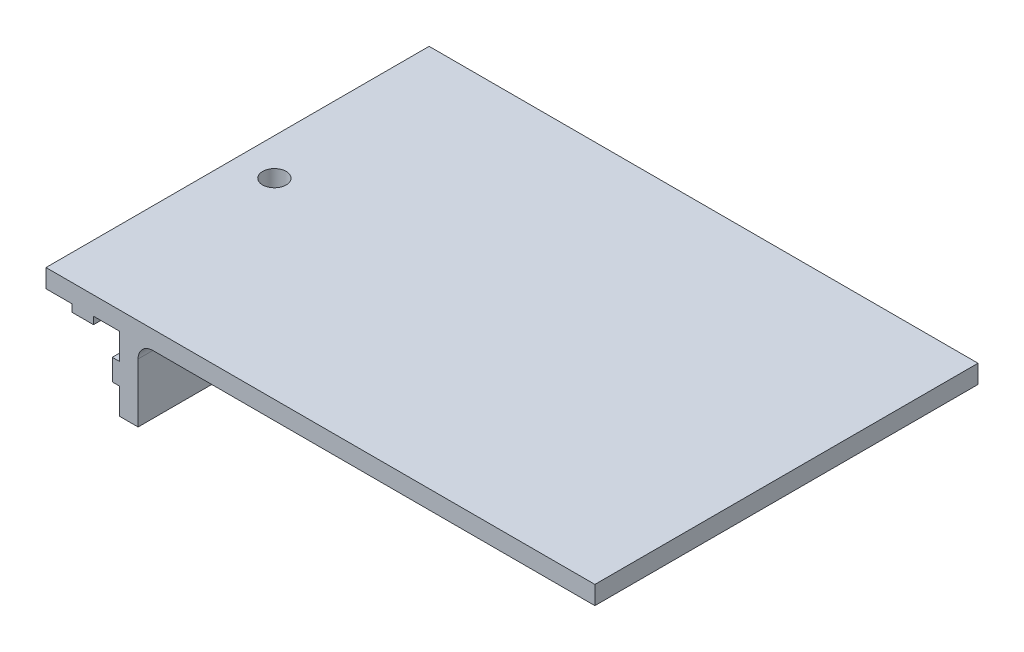
from build123d import *

# Parameters (mm, degrees)
BOSS_EXTRUDE1_DEPTH = 26
FILLET1_R           = 2
SKETCH2_R           = 1.6
CUT_EXTRUDE1_DEPTH  = 13.5
SKETCH3_R           = 1.6
CUT_EXTRUDE2_DEPTH  = 13.5


with BuildPart() as part:
    # Sketch1 → Boss-Extrude1 (new body, symmetric)
    with BuildSketch(Plane.XY):
        Polygon((62, 0), (62, 2.5), (-12.5, 2.5), (-12.5, 0), (-8.95, 0), (-8.95, -1), (-6.05, -1), (-6.05, 0), (-2.5, 0), (-2.5, -3.55), (-3.5, -3.55), (-3.5, -6.45), (-2.5, -6.45), (-2.5, -10), (0, -10), (0, 0), align=None)
    extrude(amount=BOSS_EXTRUDE1_DEPTH, both=True)

    # Fillet1
    fillet1_edges = [part.edges().sort_by_distance(p)[0] for p in [
        (0, 0, 0),
    ]]
    fillet(fillet1_edges, radius=FILLET1_R)

    # Sketch2 → Cut-Extrude1 (cut, through all)
    with BuildSketch(Plane(origin=(0, 0, 0), x_dir=(0, 0, -1), z_dir=(1, 0, 0))):
        with Locations((0, -5)):
            Circle(SKETCH2_R)
    extrude(amount=-CUT_EXTRUDE1_DEPTH, mode=Mode.SUBTRACT)

    # Sketch3 → Cut-Extrude2 (cut, through all)
    with BuildSketch(Plane(origin=(0, 2.5, 0), x_dir=(1, 0, 0), z_dir=(0, 1, 0))):
        with Locations((-7.5, 0)):
            Circle(SKETCH3_R)
    extrude(amount=-CUT_EXTRUDE2_DEPTH, mode=Mode.SUBTRACT)


solid = part.part
